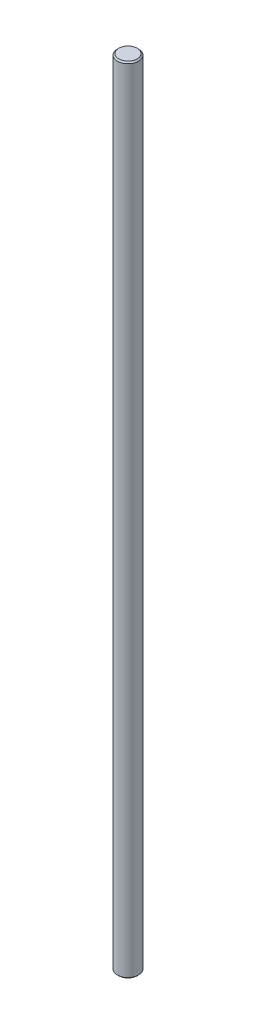
from build123d import *

# Parameters (mm, degrees)
BOSS_EXTRUDE1_DEPTH      = 150
BOSS_EXTRUDE1_DEPTH_BACK = 150
SKETCH1_R                = 4
CHAMFER1_SIZE            = 0.5


with BuildPart() as part:
    # Sketch1 → Boss-Extrude1 (new, two sides: drawn at the far end of the back side and taken through both)
    with BuildSketch(Plane(origin=(0, 0, 0), x_dir=(1, 0, 0), z_dir=(0, 1, 0)).offset(-BOSS_EXTRUDE1_DEPTH_BACK)):
        Circle(SKETCH1_R)
    extrude(amount=BOSS_EXTRUDE1_DEPTH + BOSS_EXTRUDE1_DEPTH_BACK)

    # Chamfer1
    chamfer1_edges = [part.edges().sort_by_distance(p)[0] for p in [
        (-4, -150, 0),
        (-4, 150, 0),
    ]]
    chamfer(chamfer1_edges, length=CHAMFER1_SIZE)


solid = part.part
